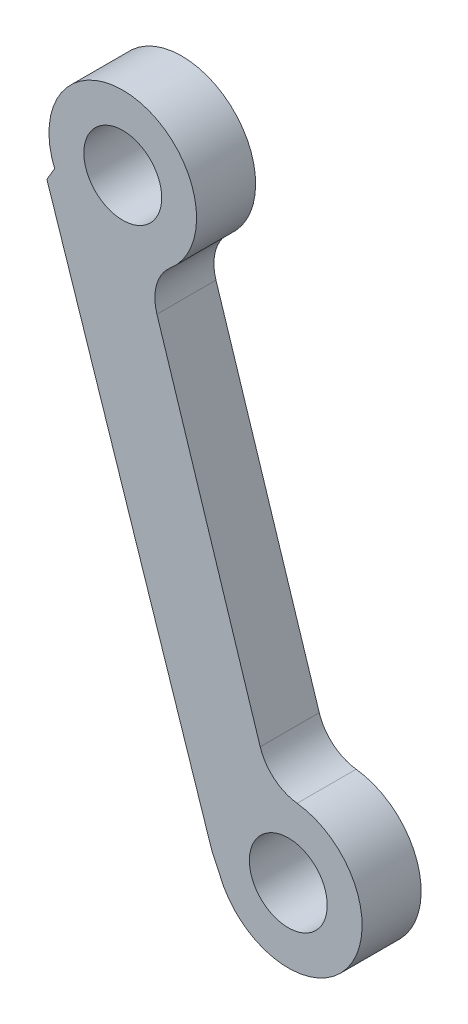
from build123d import *

# Parameters (mm, degrees)
SKETCH1_R           = 2.6375
BOSS_EXTRUDE1_DEPTH = 4


with BuildPart() as part:
    # Sketch1 → Boss-Extrude1 (new body)
    with BuildSketch(Plane.XY.offset(4)):
        with BuildLine():
            Line((17.952113198, 57.448352953), (10.955070442, 79.331722279))
            ThreePointArc((10.955070442, 79.331722279), (10.929647665, 81.056262686), (11.867204342, 82.503906776))
            ThreePointArc((11.867204342, 82.503906776), (9.81999759, 91.182758949), (4.022786968, 84.407371171))
            Line((4.022786968, 84.407371171), (3.500292698, 83.52050233))
            Line((3.500292698, 83.52050233), (14.672653681, 49.728262883))
            Line((14.672653681, 49.728262883), (15.200071751, 48.596801815))
            ThreePointArc((15.200071751, 48.596801815), (23.810416572, 47.35893823), (20.452073098, 55.383392934))
            ThreePointArc((20.452073098, 55.383392934), (18.899078146, 56.049025475), (17.952113198, 57.448352953))
        make_face()
        with Locations((19.856196321, 50.419026825)):
            Circle(SKETCH1_R, mode=Mode.SUBTRACT)
        with Locations((8.640951758, 86.323762043)):
            Circle(SKETCH1_R, mode=Mode.SUBTRACT)
    extrude(amount=-BOSS_EXTRUDE1_DEPTH)


solid = part.part
